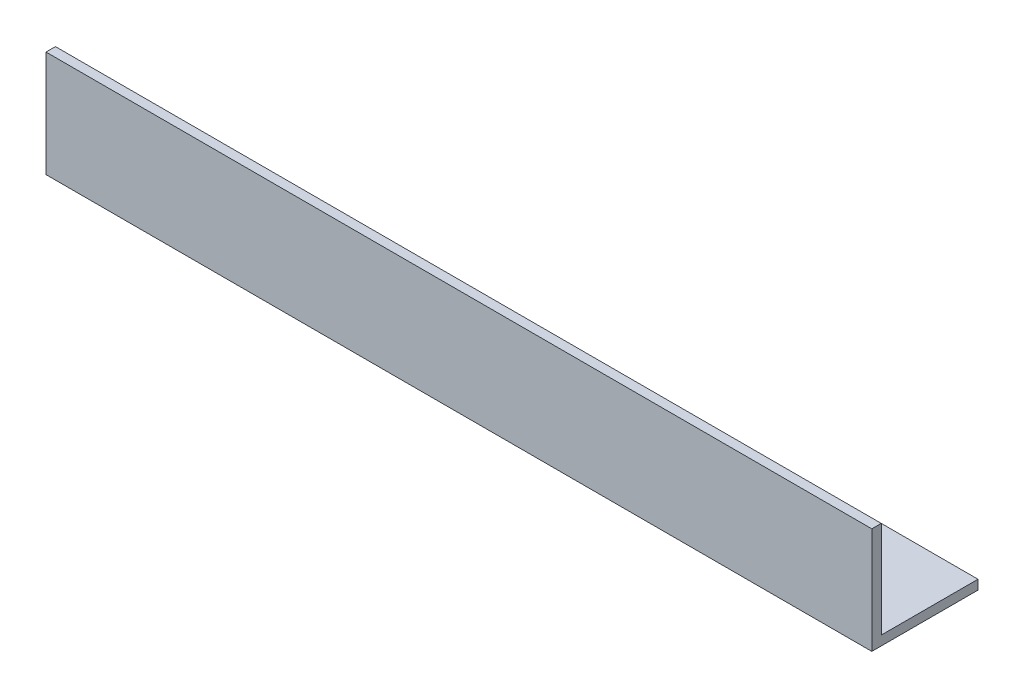
from build123d import *

# Parameters (mm, degrees)
EXTRUDE_1_DEPTH = 350


with BuildPart() as part:
    # Эскиз1 → Вытянуть-Тонкостенный1 (new body)
    with BuildSketch(Plane(origin=(0, 0, 0), x_dir=(0, 0, -1), z_dir=(1, 0, 0))):
        Polygon((0, 45), (0, 0), (45, 0), (45, 4), (4, 4), (4, 45), align=None)
    extrude(amount=EXTRUDE_1_DEPTH)


solid = part.part
